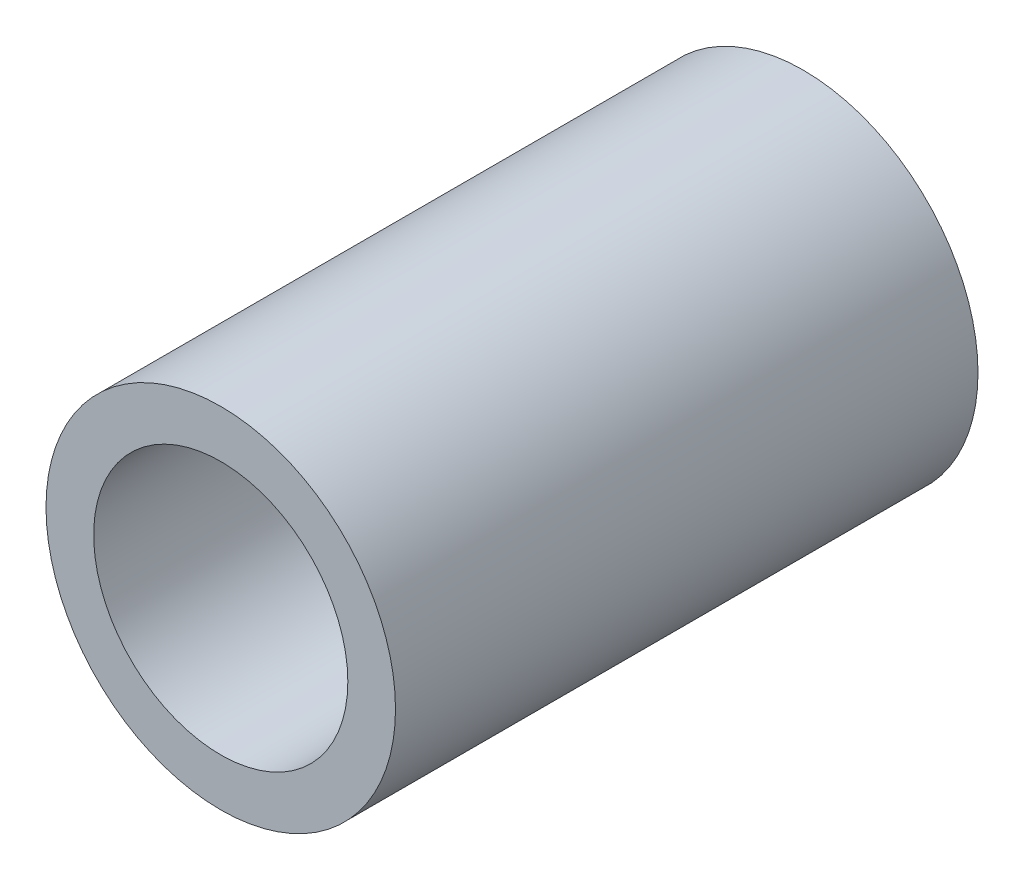
from build123d import *

# Parameters (mm, degrees)
SKETCH2_R           = 3
SKETCH2_R_2         = 2.181818182
BOSS_EXTRUDE1_DEPTH = 10


with BuildPart() as part:
    # Sketch2 → Boss-Extrude1 (new body)
    with BuildSketch(Plane.XY):
        Circle(SKETCH2_R)
        Circle(SKETCH2_R_2, mode=Mode.SUBTRACT)
    extrude(amount=BOSS_EXTRUDE1_DEPTH)


solid = part.part
